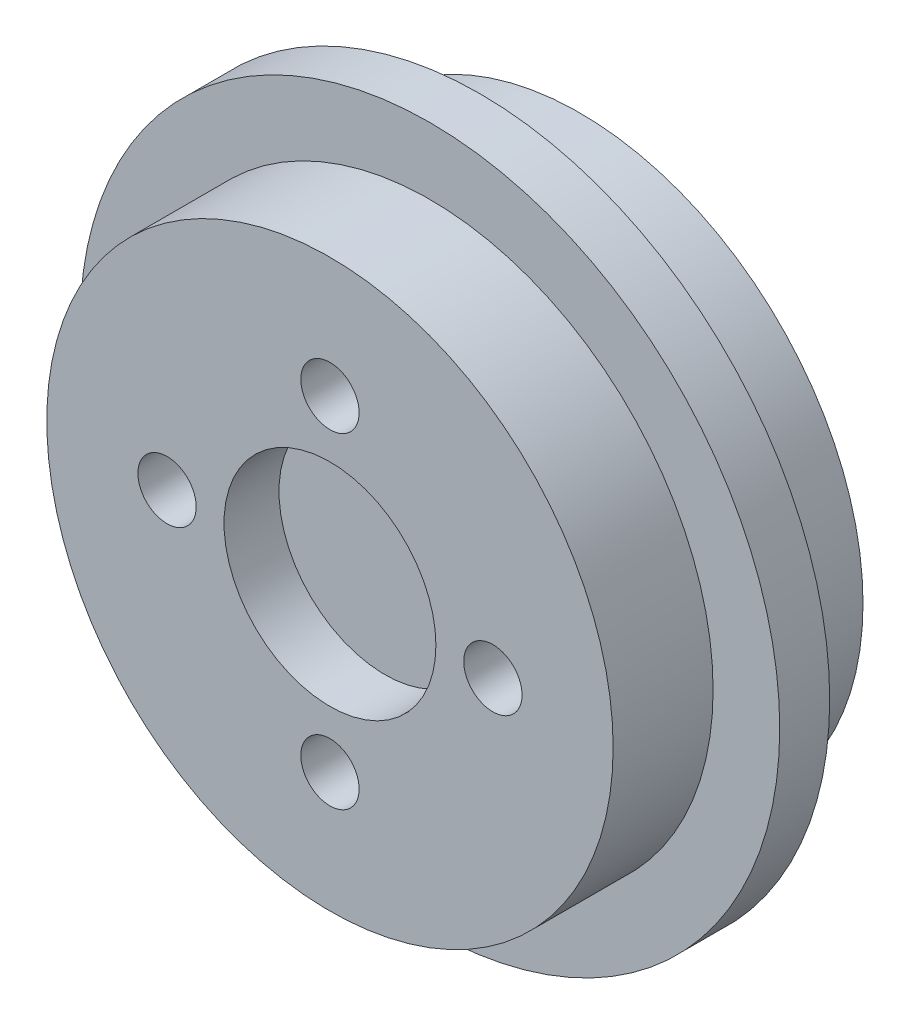
from build123d import *

# Parameters (mm, degrees)
SKETCH1_R           = 17
BOSS_EXTRUDE1_DEPTH = 15
CUT_EXTRUDE2_DEPTH  = 5
SKETCH3_R           = 1.75
CUT_EXTRUDE3_DEPTH  = 5
SKETCH4_W           = 3
SKETCH4_H           = 4
SKETCH5_R           = 6.36
CUT_EXTRUDE4_DEPTH  = 3.3


with BuildPart() as part:
    # Sketch1 → Boss-Extrude1 (new body)
    with BuildSketch(Plane.XY):
        Circle(SKETCH1_R)
    extrude(amount=BOSS_EXTRUDE1_DEPTH)

    # Sketch2 → Cut-Extrude2 (cut)
    with BuildSketch(Plane(origin=(0, 0, 0), x_dir=(-1, 0, 0), z_dir=(0, 0, -1))):
        with BuildLine():
            ThreePointArc((5.676819497, 7.303165094), (3.539821749, 8.545885676), (1.15, 9.178235124))
            ThreePointArc((1.15, 9.178235124), (0, 8.028235124), (-1.15, 9.178235124))
            ThreePointArc((-1.15, 9.178235124), (-3.539821749, 8.545885676), (-5.676819497, 7.303165094))
            ThreePointArc((-5.676819497, 7.303165094), (-5.676819497, 5.676819497), (-7.303165094, 5.676819497))
            ThreePointArc((-7.303165094, 5.676819497), (-8.545885676, 3.539821749), (-9.178235124, 1.15))
            ThreePointArc((-9.178235124, 1.15), (-8.028235124, 0), (-9.178235124, -1.15))
            ThreePointArc((-9.178235124, -1.15), (-8.545885676, -3.539821749), (-7.303165094, -5.676819497))
            ThreePointArc((-7.303165094, -5.676819497), (-5.676819497, -5.676819497), (-5.676819497, -7.303165094))
            ThreePointArc((-5.676819497, -7.303165094), (-3.539821749, -8.545885676), (-1.15, -9.178235124))
            ThreePointArc((-1.15, -9.178235124), (0, -8.028235124), (1.15, -9.178235124))
            ThreePointArc((1.15, -9.178235124), (3.539821749, -8.545885676), (5.676819497, -7.303165094))
            ThreePointArc((5.676819497, -7.303165094), (5.676819497, -5.676819497), (7.303165094, -5.676819497))
            ThreePointArc((7.303165094, -5.676819497), (8.545885676, -3.539821749), (9.178235124, -1.15))
            ThreePointArc((9.178235124, -1.15), (8.028235124, 0), (9.178235124, 1.15))
            ThreePointArc((9.178235124, 1.15), (8.545885676, 3.539821749), (7.303165094, 5.676819497))
            ThreePointArc((7.303165094, 5.676819497), (5.676819497, 5.676819497), (5.676819497, 7.303165094))
        make_face()
        with BuildLine():
            Line((9.333809512, 10.960155108), (5.676819497, 7.303165094))
            ThreePointArc((5.676819497, 7.303165094), (6.540737726, 6.540737726), (7.303165094, 5.676819497))
            Line((7.303165094, 5.676819497), (10.960155108, 9.333809512))
            ThreePointArc((10.960155108, 9.333809512), (10.960155108, 10.960155108), (9.333809512, 10.960155108))
        make_face()
        with BuildLine():
            Line((14.35, 1.15), (9.178235124, 1.15))
            ThreePointArc((9.178235124, 1.15), (9.232041348, 0.57611852), (9.25, 0))
            ThreePointArc((9.25, 0), (9.232041348, -0.57611852), (9.178235124, -1.15))
            Line((9.178235124, -1.15), (14.35, -1.15))
            ThreePointArc((14.35, -1.15), (15.5, 0), (14.35, 1.15))
        make_face()
        with BuildLine():
            Line((10.960155108, -9.333809512), (7.303165094, -5.676819497))
            ThreePointArc((7.303165094, -5.676819497), (6.540737726, -6.540737726), (5.676819497, -7.303165094))
            Line((5.676819497, -7.303165094), (9.333809512, -10.960155108))
            ThreePointArc((9.333809512, -10.960155108), (10.960155108, -10.960155108), (10.960155108, -9.333809512))
        make_face()
        with BuildLine():
            Line((1.15, -14.35), (1.15, -9.178235124))
            ThreePointArc((1.15, -9.178235124), (0, -9.25), (-1.15, -9.178235124))
            Line((-1.15, -9.178235124), (-1.15, -14.35))
            ThreePointArc((-1.15, -14.35), (0, -15.5), (1.15, -14.35))
        make_face()
        with BuildLine():
            ThreePointArc((-5.676819497, -7.303165094), (-6.540737726, -6.540737726), (-7.303165094, -5.676819497))
            Line((-7.303165094, -5.676819497), (-10.960155108, -9.333809512))
            ThreePointArc((-10.960155108, -9.333809512), (-10.960155108, -10.960155108), (-9.333809512, -10.960155108))
            Line((-9.333809512, -10.960155108), (-5.676819497, -7.303165094))
        make_face()
        with BuildLine():
            ThreePointArc((-9.178235124, -1.15), (-9.25, 0), (-9.178235124, 1.15))
            Line((-9.178235124, 1.15), (-14.35, 1.15))
            ThreePointArc((-14.35, 1.15), (-15.5, 0), (-14.35, -1.15))
            Line((-14.35, -1.15), (-9.178235124, -1.15))
        make_face()
        with BuildLine():
            ThreePointArc((-7.303165094, 5.676819497), (-6.540737726, 6.540737726), (-5.676819497, 7.303165094))
            Line((-5.676819497, 7.303165094), (-9.333809512, 10.960155108))
            ThreePointArc((-9.333809512, 10.960155108), (-10.960155108, 10.960155108), (-10.960155108, 9.333809512))
            Line((-10.960155108, 9.333809512), (-7.303165094, 5.676819497))
        make_face()
        with BuildLine():
            Line((1.15, 9.178235124), (1.15, 14.35))
            ThreePointArc((1.15, 14.35), (0, 15.5), (-1.15, 14.35))
            Line((-1.15, 14.35), (-1.15, 9.178235124))
            ThreePointArc((-1.15, 9.178235124), (0, 9.25), (1.15, 9.178235124))
        make_face()
        with BuildLine():
            ThreePointArc((5.676819497, -7.303165094), (6.540737726, -6.540737726), (7.303165094, -5.676819497))
            ThreePointArc((7.303165094, -5.676819497), (5.676819497, -5.676819497), (5.676819497, -7.303165094))
        make_face()
        with BuildLine():
            ThreePointArc((-1.15, 9.178235124), (0, 8.028235124), (1.15, 9.178235124))
            ThreePointArc((1.15, 9.178235124), (0, 9.25), (-1.15, 9.178235124))
        make_face()
        with BuildLine():
            ThreePointArc((7.303165094, 5.676819497), (6.540737726, 6.540737726), (5.676819497, 7.303165094))
            ThreePointArc((5.676819497, 7.303165094), (5.676819497, 5.676819497), (7.303165094, 5.676819497))
        make_face()
        with BuildLine():
            ThreePointArc((9.25, 0), (9.232041348, 0.57611852), (9.178235124, 1.15))
            ThreePointArc((9.178235124, 1.15), (8.028235124, 0), (9.178235124, -1.15))
            ThreePointArc((9.178235124, -1.15), (9.232041348, -0.57611852), (9.25, 0))
        make_face()
        with BuildLine():
            ThreePointArc((-1.15, -9.178235124), (0, -9.25), (1.15, -9.178235124))
            ThreePointArc((1.15, -9.178235124), (0, -8.028235124), (-1.15, -9.178235124))
        make_face()
        with BuildLine():
            ThreePointArc((-5.676819497, -7.303165094), (-5.676819497, -5.676819497), (-7.303165094, -5.676819497))
            ThreePointArc((-7.303165094, -5.676819497), (-6.540737726, -6.540737726), (-5.676819497, -7.303165094))
        make_face()
        with BuildLine():
            ThreePointArc((-9.178235124, -1.15), (-8.028235124, 0), (-9.178235124, 1.15))
            ThreePointArc((-9.178235124, 1.15), (-9.25, 0), (-9.178235124, -1.15))
        make_face()
        with BuildLine():
            ThreePointArc((-7.303165094, 5.676819497), (-5.676819497, 5.676819497), (-5.676819497, 7.303165094))
            ThreePointArc((-5.676819497, 7.303165094), (-6.540737726, 6.540737726), (-7.303165094, 5.676819497))
        make_face()
    extrude(amount=-CUT_EXTRUDE2_DEPTH, mode=Mode.SUBTRACT)

    # Sketch3 → Cut-Extrude3 (cut)
    with BuildSketch(Plane.XY.offset(15)):
        with Locations((0, 9.78)):
            Circle(SKETCH3_R)
        with Locations((9.78, 0)):
            Circle(SKETCH3_R)
        with Locations((0, -9.78)):
            Circle(SKETCH3_R)
        with Locations((-9.78, 0)):
            Circle(SKETCH3_R)
    extrude(amount=-CUT_EXTRUDE3_DEPTH, mode=Mode.SUBTRACT)

    # Sketch4 → Revolve1 (revolve)
    with BuildSketch(Plane(origin=(0, 0, 0), x_dir=(0, 0, -1), z_dir=(1, 0, 0))):
        with Locations((-7.5, -19)):
            Rectangle(SKETCH4_W, SKETCH4_H)
    revolve(axis=Axis((0, 0, 20.375620023), (0, 0, -1)))

    # Sketch5 → Cut-Extrude4 (cut)
    with BuildSketch(Plane.XY.offset(15)):
        Circle(SKETCH5_R)
    extrude(amount=-CUT_EXTRUDE4_DEPTH, mode=Mode.SUBTRACT)


solid = part.part
